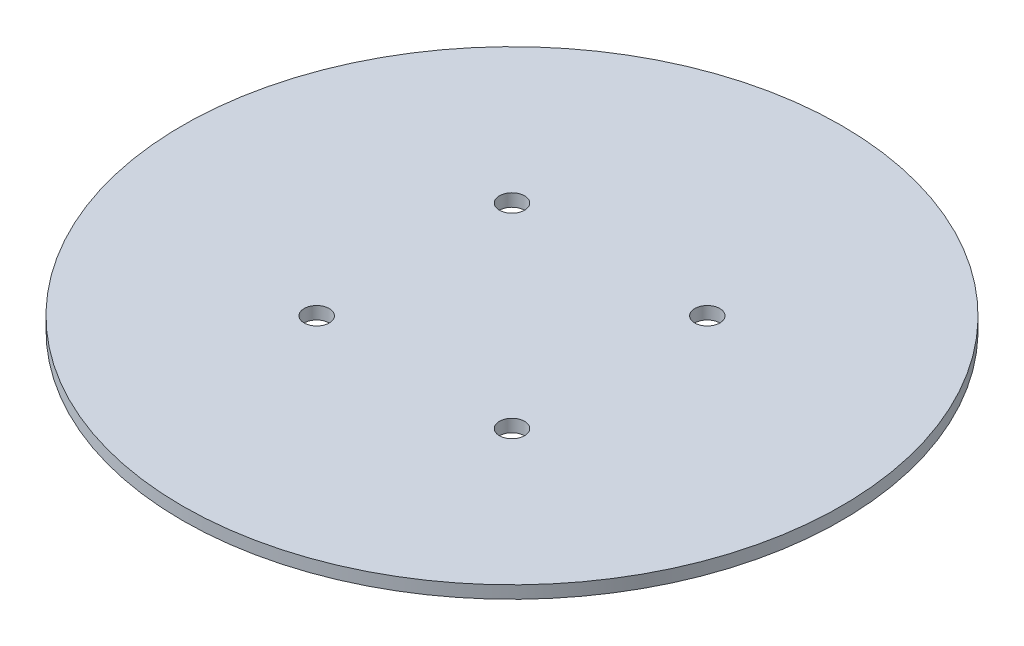
from build123d import *

# Parameters (mm, degrees)
ESBO_O1_R                = 105
RESSALTO_EXTRUS_O1_DEPTH = 4
ESBO_O5_R                = 4
CORTE_EXTRUS_O1_DEPTH    = 10


with BuildPart() as part:
    # Esboço1 → Ressalto-extrusão1 (new body)
    with BuildSketch(Plane(origin=(0, 0, 0), x_dir=(1, 0, 0), z_dir=(0, 1, 0))):
        Circle(ESBO_O1_R)
    extrude(amount=RESSALTO_EXTRUS_O1_DEPTH)

    # Esboço5 → Corte-extrusão1 (cut)
    with BuildSketch(Plane(origin=(0, 4, 0), x_dir=(1, 0, 0), z_dir=(0, 1, 0))):
        with Locations((31.112698372, -31.112698372)):
            Circle(ESBO_O5_R)
        with Locations((31.112698372, 31.112698372)):
            Circle(ESBO_O5_R)
        with Locations((-31.112698372, 31.112698372)):
            Circle(ESBO_O5_R)
        with Locations((-31.112698372, -31.112698372)):
            Circle(ESBO_O5_R)
    extrude(amount=-CORTE_EXTRUS_O1_DEPTH, mode=Mode.SUBTRACT)


solid = part.part
